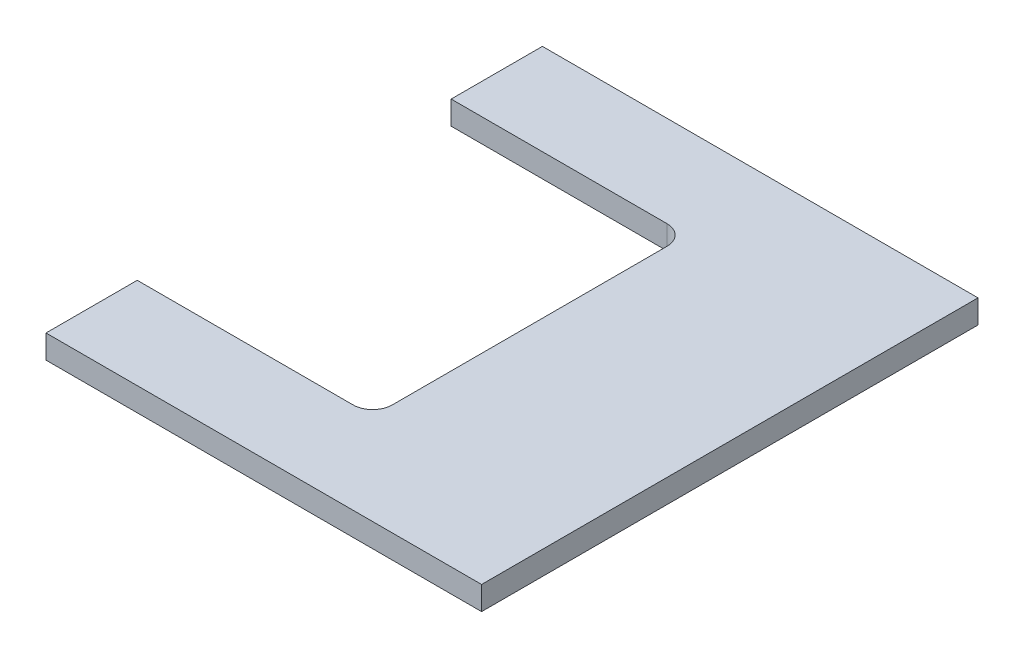
from build123d import *

# Parameters (mm, degrees)
SKETCH1_W           = 111
SKETCH1_H           = 126.5
BOSS_EXTRUDE1_DEPTH = 6
SKETCH2_W           = 60
SKETCH2_H           = 80
CUT_EXTRUDE1_DEPTH  = 7
FILLET1_R           = 5


with BuildPart() as part:
    # Sketch1 → Boss-Extrude1 (new body)
    with BuildSketch(Plane(origin=(0, 0, 0), x_dir=(1, 0, 0), z_dir=(0, 1, 0))):
        with Locations((55.5, 63.25)):
            Rectangle(SKETCH1_W, SKETCH1_H)
    extrude(amount=BOSS_EXTRUDE1_DEPTH)

    # Sketch2 → Cut-Extrude1 (cut, through all)
    with BuildSketch(Plane(origin=(0, 6, 0), x_dir=(1, 0, 0), z_dir=(0, 1, 0))):
        with Locations((30, 63.25)):
            Rectangle(SKETCH2_W, SKETCH2_H)
    extrude(amount=-CUT_EXTRUDE1_DEPTH, mode=Mode.SUBTRACT)

    # Fillet1
    fillet1_edges = [part.edges().sort_by_distance(p)[0] for p in [
        (60, 3, -103.25),
        (60, 3, -23.25),
    ]]
    fillet(fillet1_edges, radius=FILLET1_R)


solid = part.part
